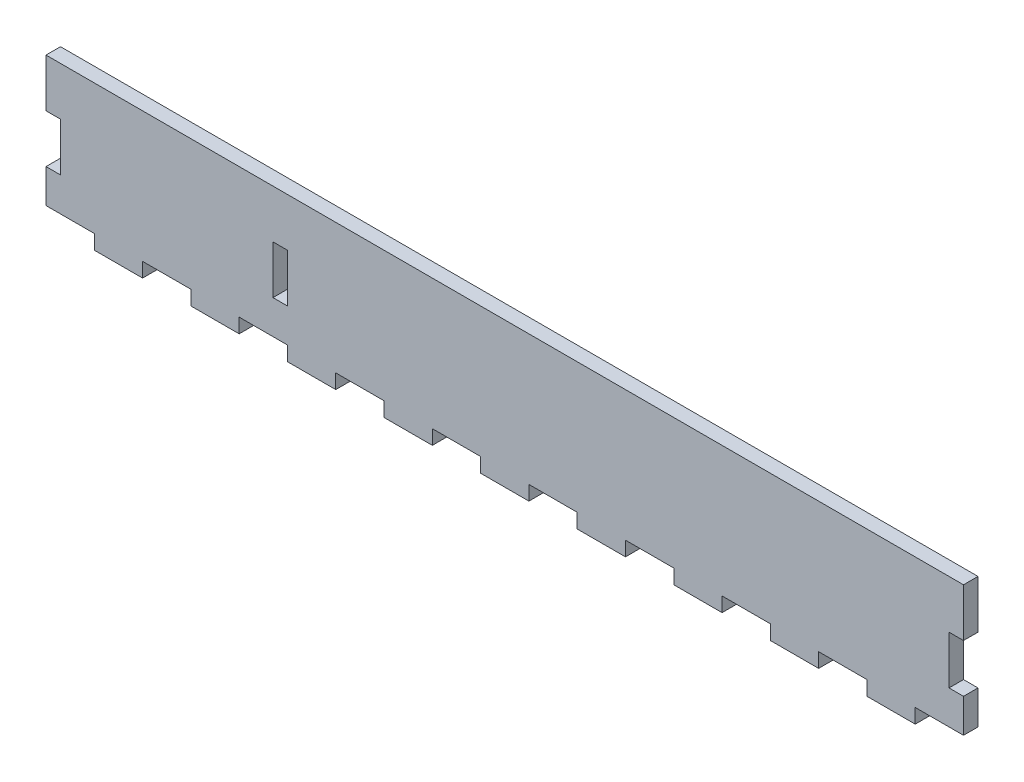
from build123d import *

# Parameters (mm, degrees)
BOSS_EXTRUDE1_DEPTH = 6
SKETCH2_W           = 6
SKETCH2_H           = 20
CUT_EXTRUDE1_DEPTH  = 10
SKETCH3_W           = 6
SKETCH3_H           = 20
CUT_EXTRUDE2_DEPTH  = 10
SKETCH4_W           = 20
SKETCH4_H           = 6
CUT_EXTRUDE3_DEPTH  = 10
LPATTERN1_COUNT     = 10
LPATTERN1_PITCH     = 40
SKETCH5_W           = 6
SKETCH5_H           = 20
CUT_EXTRUDE4_DEPTH  = 10


with BuildPart() as part:
    # Sketch1 → Boss-Extrude1 (new body)
    with BuildSketch(Plane.XY):
        Polygon((-114.513362239, -81.437063232), (-114.513362239, -71.437063232), (-14.513362239, -71.437063232), (265.486637761, -71.437063232), (265.486637761, -131.437063232), (-14.513362239, -131.437063232), (-114.513362239, -131.437063232), align=None)
    extrude(amount=BOSS_EXTRUDE1_DEPTH)

    # Sketch2 → Cut-Extrude1 (cut)
    with BuildSketch(Plane.XY.offset(6)):
        with Locations((-111.513362239, -101.437063232)):
            Rectangle(SKETCH2_W, SKETCH2_H)
    extrude(amount=-CUT_EXTRUDE1_DEPTH, mode=Mode.SUBTRACT)

    # Sketch3 → Cut-Extrude2 (cut)
    with BuildSketch(Plane.XY.offset(6)):
        with Locations((-17.513362239, -101.437063232)):
            Rectangle(SKETCH3_W, SKETCH3_H)
    extrude(amount=-CUT_EXTRUDE2_DEPTH, mode=Mode.SUBTRACT)

    # Sketch4 → Cut-Extrude3 (cut)
    with BuildSketch(Plane.XY.offset(6)):
        with Locations((-104.513362239, -128.437063232)):
            Rectangle(SKETCH4_W, SKETCH4_H)
    cut_extrude3 = extrude(amount=-CUT_EXTRUDE3_DEPTH, mode=Mode.SUBTRACT)

    # LPattern1: Cut-Extrude3 ×10
    with Locations(*[(i * LPATTERN1_PITCH, 0, 0) for i in range(1, LPATTERN1_COUNT)]):
        add(cut_extrude3, mode=Mode.SUBTRACT)

    # Sketch5 → Cut-Extrude4 (cut)
    with BuildSketch(Plane.XY.offset(6)):
        with Locations((262.486637761, -101.437063232)):
            Rectangle(SKETCH5_W, SKETCH5_H)
    extrude(amount=-CUT_EXTRUDE4_DEPTH, mode=Mode.SUBTRACT)


solid = part.part
